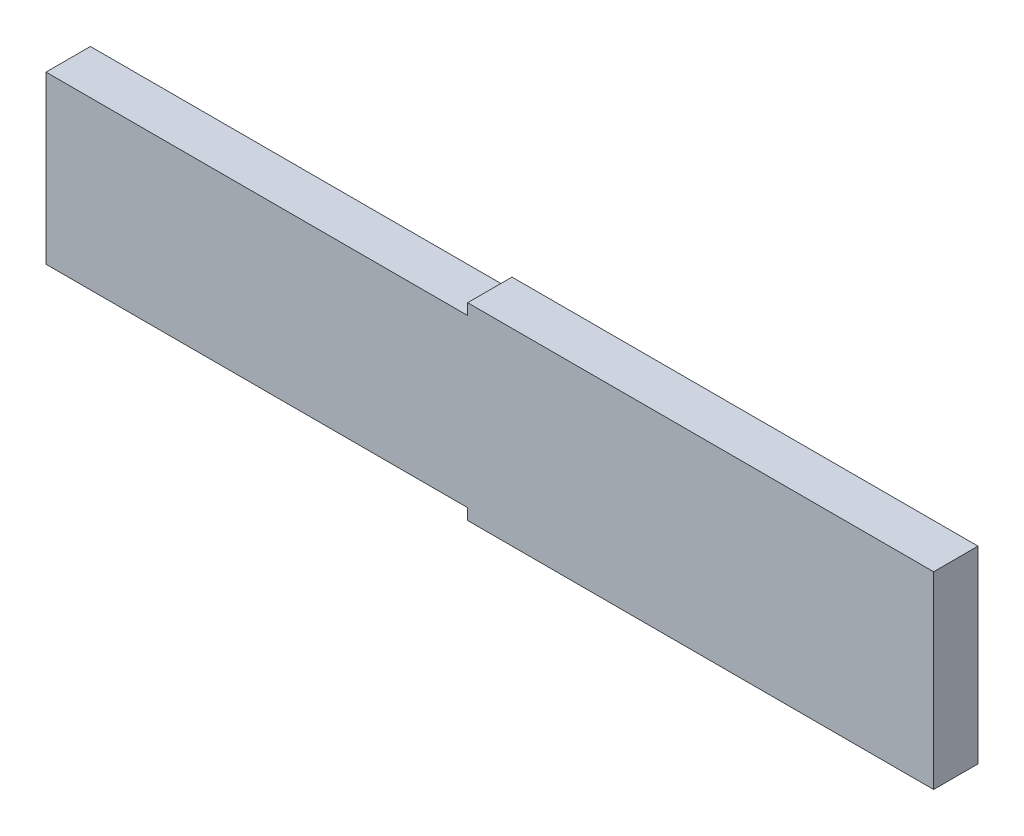
from build123d import *

# Parameters (mm, degrees)
AUFSATZ_LINEAR_AUSTRAGEN1_DEPTH = 4


with BuildPart() as part:
    # Skizze1 → Aufsatz-Linear austragen1 (new body)
    with BuildSketch(Plane.XY):
        Polygon((-38, -7.5), (-38, 7.5), (0, 7.5), (0, 8.5), (42, 8.5), (42, -8.5), (0, -8.5), (0, -7.5), align=None)
    extrude(amount=AUFSATZ_LINEAR_AUSTRAGEN1_DEPTH)


solid = part.part
